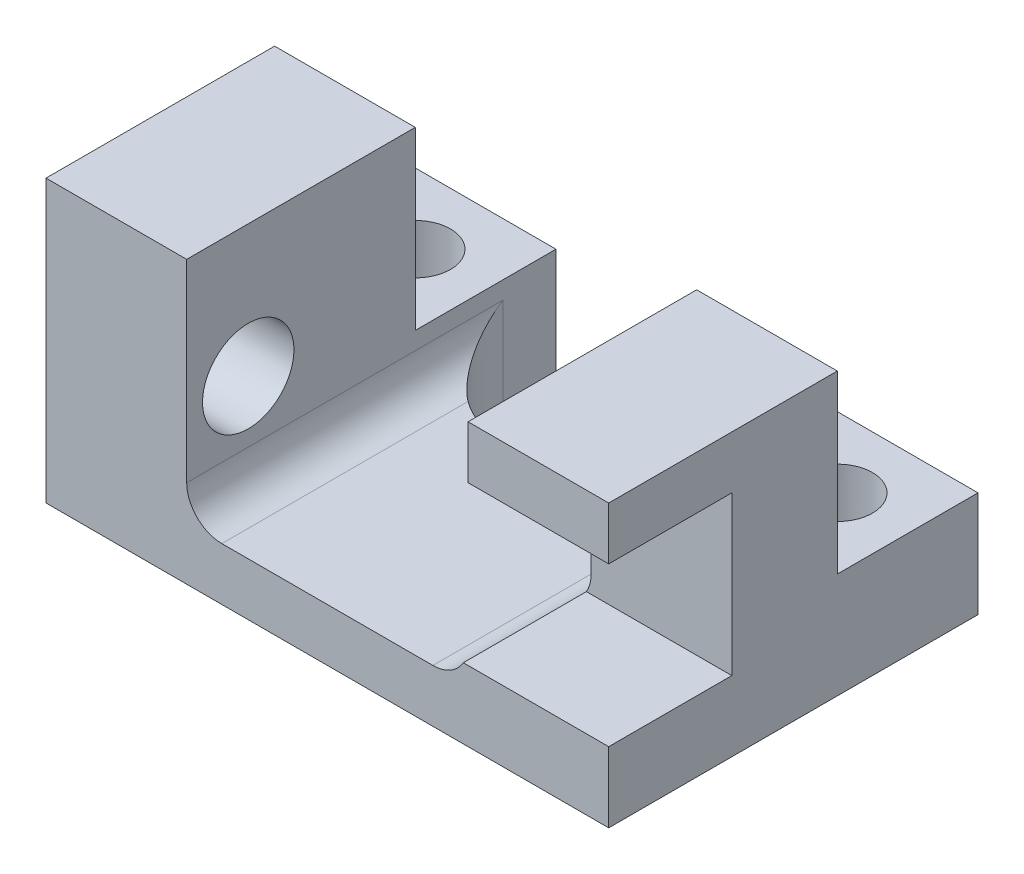
from build123d import *

# Parameters (mm, degrees)
SKETCH1_W                  = 16
SKETCH1_H                  = 6.5
BOSS_EXTRUDE1_DEPTH        = 4
SKETCH2_W                  = 8
SKETCH2_H                  = 6.5
CUT_EXTRUDE1_DEPTH         = 6.5
SKETCH10_W                 = 4
SKETCH10_H                 = 4
BOSS_EXTRUDE2_DEPTH        = 3
M1_6_CLEARANCE_HOLE1_D     = 2
M1_6_CLEARANCE_HOLE1_DEPTH = 4
M1_6_CLEARANCE_HOLE1_TIP   = 0.600860619
FILLET1_R                  = 1
FILLET2_R                  = 2.5
SKETCH14_W                 = 3.5
SKETCH14_H                 = 4.5
CUT_EXTRUDE3_DEPTH         = 5
M2_CLEARANCE_HOLE3_D       = 2.6
M2_CLEARANCE_HOLE3_DEPTH   = 4
M2_CLEARANCE_HOLE3_TIP     = 0.781118805


with BuildPart() as part:
    # Sketch1 → Boss-Extrude1 (new body, symmetric)
    with BuildSketch(Plane(origin=(0, 0, 0), x_dir=(1, 0, 0), z_dir=(0, 1, 0))):
        Rectangle(SKETCH1_W, SKETCH1_H)
    extrude(amount=BOSS_EXTRUDE1_DEPTH, both=True)

    # Sketch2 → Cut-Extrude1 (cut)
    with BuildSketch(Plane(origin=(0, 4, 5), x_dir=(1, 0, 0), z_dir=(0, -1, 0))):
        with Locations((0, -5)):
            Rectangle(SKETCH2_W, SKETCH2_H)
    extrude(amount=CUT_EXTRUDE1_DEPTH, mode=Mode.SUBTRACT)

    # Sketch10 → Boss-Extrude2 (add)
    with BuildSketch(Plane.XZ.offset(4)):
        with Locations((6, -5.25)):
            Rectangle(SKETCH10_W, SKETCH10_H)
        with Locations((-6, -5.25)):
            Rectangle(SKETCH10_W, SKETCH10_H)
    extrude(amount=-BOSS_EXTRUDE2_DEPTH)

    # M1.6 Clearance Hole1
    with Locations(Plane(origin=(0, -1, 0), x_dir=(1, 0, 0), z_dir=(0, 1, 0))):
        with Locations((6, 5.25), (-6, 5.25)):
            Hole(M1_6_CLEARANCE_HOLE1_D / 2, depth=M1_6_CLEARANCE_HOLE1_DEPTH)
            with Locations((0, 0, -(M1_6_CLEARANCE_HOLE1_DEPTH + M1_6_CLEARANCE_HOLE1_TIP / 2))):  # 118° drill point
                Cone(0, M1_6_CLEARANCE_HOLE1_D / 2, M1_6_CLEARANCE_HOLE1_TIP, mode=Mode.SUBTRACT)

    # Fillet1
    fillet1_edges = [part.edges().sort_by_distance(p)[0] for p in [
        (4, -2.5, 0),
        (-4, -2.5, 0),
    ]]
    fillet(fillet1_edges, radius=FILLET1_R)

    # Fillet2
    fillet2_edges = [part.edges().sort_by_distance(p)[0] for p in [
        (-4, -3.25, -3.25),
        (4, -3.25, -3.25),
    ]]
    fillet(fillet2_edges, radius=FILLET2_R)

    # Sketch14 → Cut-Extrude3 (cut)
    with BuildSketch(Plane(origin=(8, 0, 0), x_dir=(0, 0, -1), z_dir=(1, 0, 0))):
        with Locations((-1.5, 0.25)):
            Rectangle(SKETCH14_W, SKETCH14_H)
    extrude(amount=-CUT_EXTRUDE3_DEPTH, mode=Mode.SUBTRACT)

    # M2 Clearance Hole3
    with Locations(Plane.ZY.offset(8)):
        with Locations((1.5, 0.25)):
            Hole(M2_CLEARANCE_HOLE3_D / 2, depth=M2_CLEARANCE_HOLE3_DEPTH)
            with Locations((0, 0, -(M2_CLEARANCE_HOLE3_DEPTH + M2_CLEARANCE_HOLE3_TIP / 2))):  # 118° drill point
                Cone(0, M2_CLEARANCE_HOLE3_D / 2, M2_CLEARANCE_HOLE3_TIP, mode=Mode.SUBTRACT)


solid = part.part
